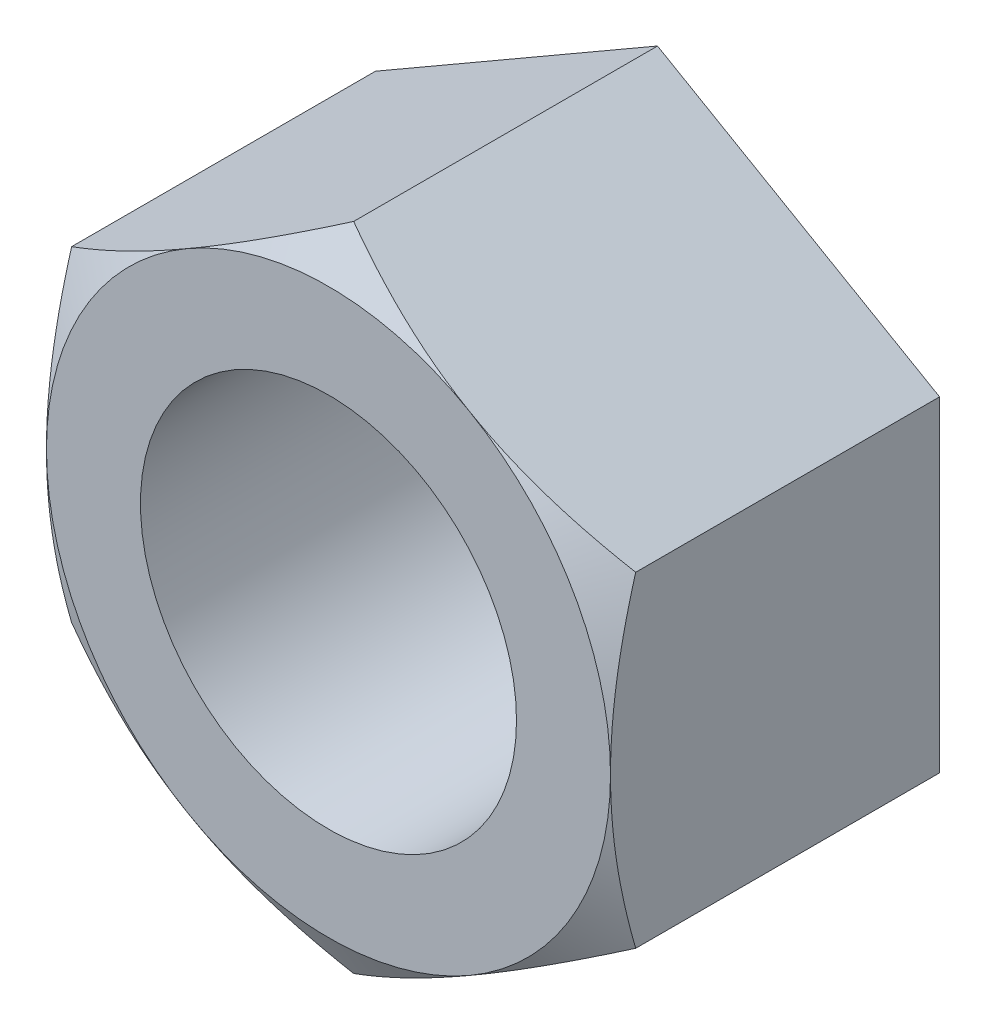
from build123d import *

# Parameters (mm, degrees)
SKETCH1_R         = 7.9375
EXTRUDE1_DEPTH    = 6.9453125
SKETCH7_OUTSIDE_W = 121.588
SKETCH7_OUTSIDE_H = 125.272
SKETCH7_OUTSIDE_R = 11.90625
EXTRUDE2_DEPTH    = 25.4
EXTRUDE2_TAPER    = 60


with BuildPart() as part:
    # Sketch1 → Extrude1 (new body, symmetric)
    with BuildSketch(Plane.XY):
        Polygon((-11.90625, 6.874076643), (-11.90625, -6.874076643), (0, -13.748153285), (11.90625, -6.874076643), (11.90625, 6.874076643), (0, 13.748153285), align=None)
        Circle(SKETCH1_R, mode=Mode.SUBTRACT)
    extrude(amount=EXTRUDE1_DEPTH, both=True)

    # Sketch7 outside → Extrude2 (cut)
    with BuildSketch(Plane.XY.offset(6.9453125)):
        Rectangle(SKETCH7_OUTSIDE_W, SKETCH7_OUTSIDE_H)
        Circle(SKETCH7_OUTSIDE_R, mode=Mode.SUBTRACT)
    extrude(amount=-EXTRUDE2_DEPTH, taper=EXTRUDE2_TAPER, mode=Mode.SUBTRACT)


solid = part.part
